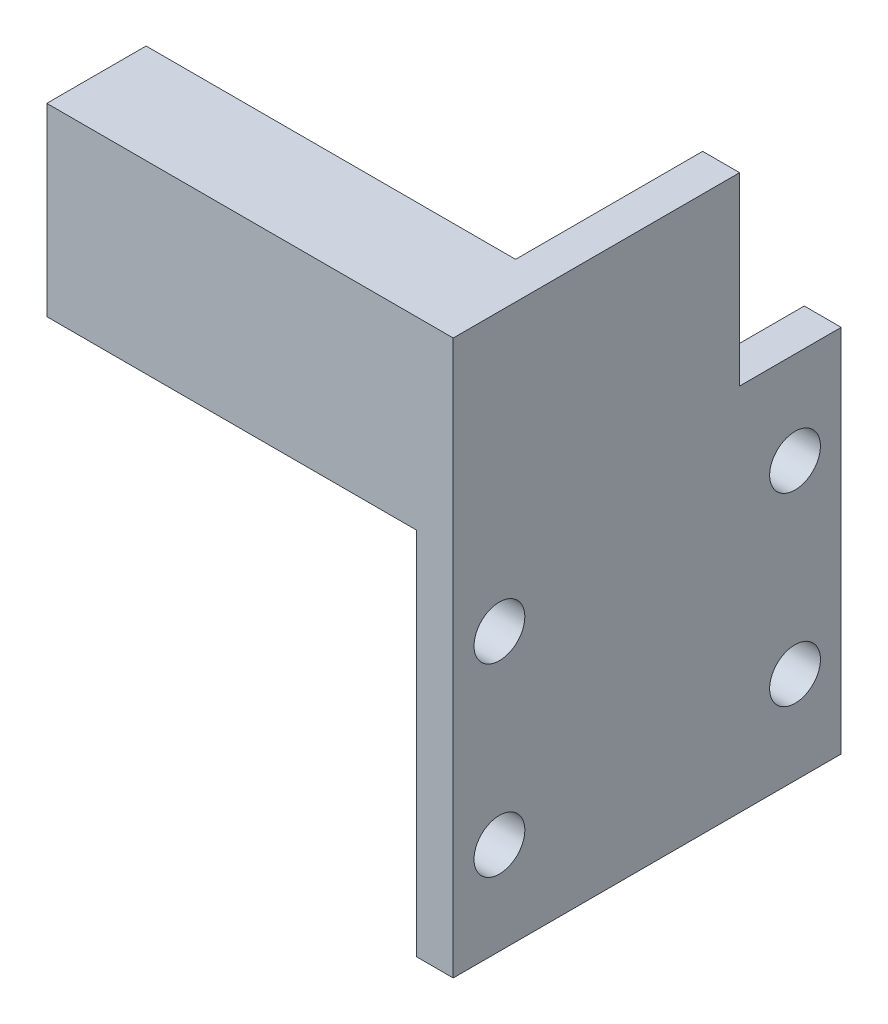
from build123d import *

# Parameters (mm, degrees)
SKETCH1_W           = 42
SKETCH1_H           = 40
SKETCH1_R           = 2.75
BOSS_EXTRUDE1_DEPTH = 4
BOSS_EXTRUDE2_DEPTH = 20


with BuildPart() as part:
    # Sketch1 → Boss-Extrude1 (new body)
    with BuildSketch(Plane(origin=(0, 0, 0), x_dir=(0, 0, -1), z_dir=(1, 0, 0))):
        with Locations((21, 20)):
            Rectangle(SKETCH1_W, SKETCH1_H)
        with Locations((5, 30)):
            Circle(SKETCH1_R, mode=Mode.SUBTRACT)
        with Locations((5, 10)):
            Circle(SKETCH1_R, mode=Mode.SUBTRACT)
        with Locations((37, 10)):
            Circle(SKETCH1_R, mode=Mode.SUBTRACT)
        with Locations((37, 30)):
            Circle(SKETCH1_R, mode=Mode.SUBTRACT)
    extrude(amount=-BOSS_EXTRUDE1_DEPTH)

    # Sketch3 → Boss-Extrude2 (add)
    with BuildSketch(Plane(origin=(0, 40, 0), x_dir=(1, 0, 0), z_dir=(0, 1, 0))):
        Polygon((-4, 31), (-4, 10.75), (-44, 10.75), (-44, 0), (0, 0), (0, 31), align=None)
    extrude(amount=BOSS_EXTRUDE2_DEPTH)


solid = part.part
